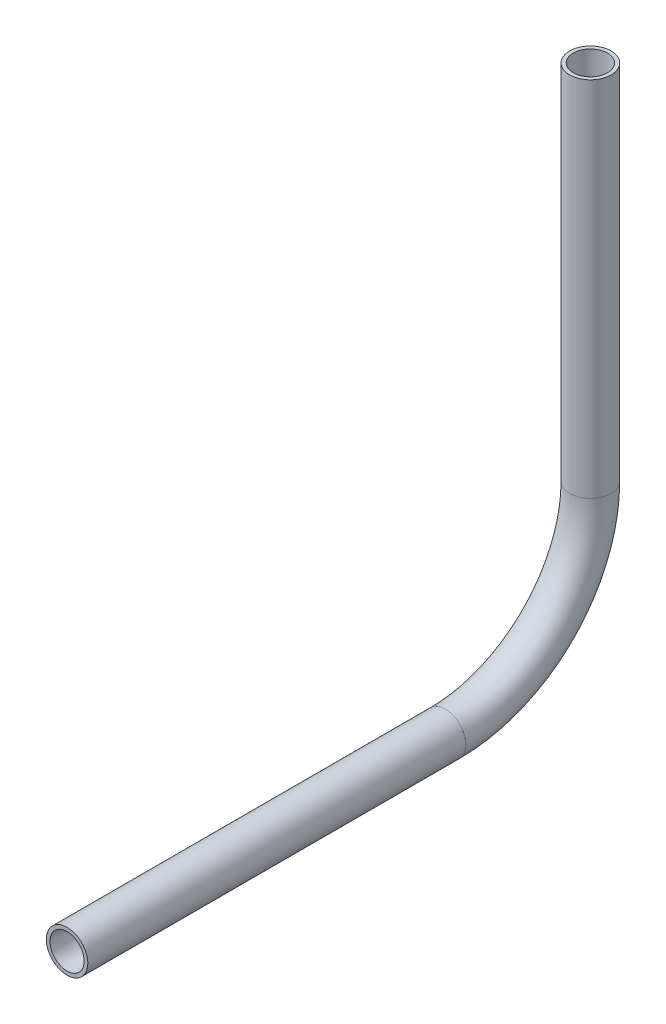
from build123d import *

# Parameters (mm, degrees)
SKETCH11_R                = 3.175
SKETCH11_R_2              = 2.6162
PIPE_0_5_SCH_40_1_DEPTH   = 57.867055849
SKETCH11_ON_SEGMENT_2_R   = 3.175
SKETCH11_ON_SEGMENT_2_R_2 = 2.6162
PIPE_0_5_SCH_40_1_2_ANGLE = 90
SKETCH11_ON_SEGMENT_3_R   = 3.175
SKETCH11_ON_SEGMENT_3_R_2 = 2.6162
PIPE_0_5_SCH_40_1_3_DEPTH = 55.470107083


with BuildPart() as part:
    # Sketch11 → Pipe 0.5 SCH 40(1) (new body)
    with BuildSketch(Plane(origin=(0, 251.505538406, 132.634510624), x_dir=(0, 1, 0), z_dir=(0, 0, -1))):
        Circle(SKETCH11_R)
        Circle(SKETCH11_R_2, mode=Mode.SUBTRACT)
    extrude(amount=PIPE_0_5_SCH_40_1_DEPTH)


with BuildPart() as body_2:
    # Sketch11 on segment 2 (carried to the start of arc 2) → Pipe 0.5 SCH 40_1 2 (revolve)
    with BuildSketch(Plane(origin=(0, 251.505538406, 74.767454775), x_dir=(0, 1, 0), z_dir=(0, 0, -1))):
        Circle(SKETCH11_ON_SEGMENT_2_R)
        Circle(SKETCH11_ON_SEGMENT_2_R_2, mode=Mode.SUBTRACT)
    revolve(axis=Axis((0, 273.730538406, 74.767454775), (1, 0, 0)), revolution_arc=PIPE_0_5_SCH_40_1_2_ANGLE)


with BuildPart() as body_3:
    # Sketch11 on segment 3 (carried to segment 3) → Pipe 0.5 SCH 40_1 3 (new body)
    with BuildSketch(Plane(origin=(0, 273.730538406, 52.542454775), x_dir=(0, 0, 1), z_dir=(0, 1, 0))):
        Circle(SKETCH11_ON_SEGMENT_3_R)
        Circle(SKETCH11_ON_SEGMENT_3_R_2, mode=Mode.SUBTRACT)
    extrude(amount=PIPE_0_5_SCH_40_1_3_DEPTH)


solid = Compound([part.part, body_2.part, body_3.part])
